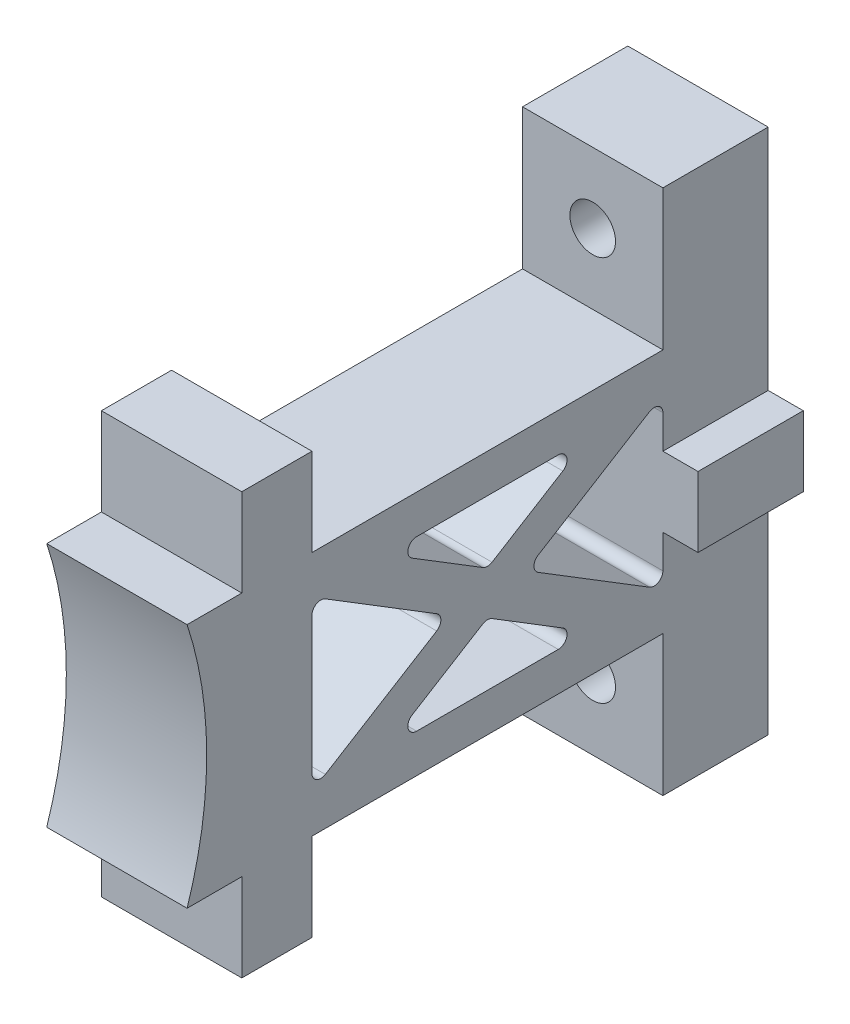
from build123d import *

# Parameters (mm, degrees)
BOSS_EXTRUDE1_DEPTH = 10.16
CUT_EXTRUDE1_DEPTH  = 21.32
SKETCH3_R           = 3.302
CUT_EXTRUDE2_DEPTH  = 16.24
SKETCH4_W           = 15.24
SKETCH4_H           = 10.16
BOSS_EXTRUDE2_DEPTH = 5.08


with BuildPart() as part:
    # Sketch1 → Boss-Extrude1 (new body, symmetric)
    with BuildSketch(Plane(origin=(0, 0, 0), x_dir=(0, 0, -1), z_dir=(1, 0, 0))):
        with BuildLine():
            Line((54.313848142, 17.78), (62.23, 17.78))
            Line((62.23, 17.78), (62.23, 30.48))
            Line((62.23, 30.48), (72.39, 30.48))
            Line((72.39, 30.48), (72.39, 17.78))
            Line((72.39, 17.78), (123.19, 17.78))
            Line((123.19, 17.78), (123.19, 38.1))
            Line((123.19, 38.1), (138.43, 38.1))
            Line((138.43, 38.1), (138.43, -38.1))
            Line((138.43, -38.1), (123.19, -38.1))
            Line((123.19, -38.1), (123.19, -17.78))
            Line((123.19, -17.78), (72.39, -17.78))
            Line((72.39, -17.78), (72.39, -30.48))
            Line((72.39, -30.48), (62.23, -30.48))
            Line((62.23, -30.48), (62.23, -17.78))
            Line((62.23, -17.78), (54.313848142, -17.78))
            ThreePointArc((54.313848142, -17.78), (57.15, 0), (54.313848142, 17.78))
        make_face()
    extrude(amount=BOSS_EXTRUDE1_DEPTH, both=True)

    # Sketch2 → Cut-Extrude1 (cut, through all)
    with BuildSketch(Plane(origin=(10.16, 0, 0), x_dir=(0, 0, -1), z_dir=(1, 0, 0))):
        with BuildLine():
            Line((72.39, 9.91925318), (72.39, -9.91925318))
            ThreePointArc((72.39, -9.91925318), (73.040490814, -11.02790478), (74.325603731, -11.000859243))
            Line((74.325603731, -11.000859243), (90.444390149, -1.081606062))
            ThreePointArc((90.444390149, -1.081606062), (91.048786418, 0), (90.444390149, 1.081606062))
            Line((90.444390149, 1.081606062), (74.325603731, 11.000859243))
            ThreePointArc((74.325603731, 11.000859243), (73.040490814, 11.02790478), (72.39, 9.91925318))
        make_face()
        with BuildLine():
            Line((123.19, 9.91925318), (123.19, -9.91925318))
            ThreePointArc((123.19, -9.91925318), (122.539509186, -11.02790478), (121.254396269, -11.000859243))
            Line((121.254396269, -11.000859243), (105.135609851, -1.081606062))
            ThreePointArc((105.135609851, -1.081606062), (104.531213582, 0), (105.135609851, 1.081606062))
            Line((105.135609851, 1.081606062), (121.254396269, 11.000859243))
            ThreePointArc((121.254396269, 11.000859243), (122.539509186, 11.02790478), (123.19, 9.91925318))
        make_face()
        with BuildLine():
            Line((86.873499611, 9.840393938), (97.124396269, 3.53214984))
            ThreePointArc((97.124396269, 3.53214984), (97.79, 3.343755902), (98.455603731, 3.53214984))
            Line((98.455603731, 3.53214984), (108.706500389, 9.840393938))
            ThreePointArc((108.706500389, 9.840393938), (109.262890869, 11.267875918), (108.040896659, 12.192))
            Line((108.040896659, 12.192), (87.539103341, 12.192))
            ThreePointArc((87.539103341, 12.192), (86.317109131, 11.267875918), (86.873499611, 9.840393938))
        make_face()
        with BuildLine():
            Line((87.539103341, -12.192), (108.040896659, -12.192))
            ThreePointArc((108.040896659, -12.192), (109.262890869, -11.267875918), (108.706500389, -9.840393938))
            Line((108.706500389, -9.840393938), (98.455603731, -3.53214984))
            ThreePointArc((98.455603731, -3.53214984), (97.79, -3.343755902), (97.124396269, -3.53214984))
            Line((97.124396269, -3.53214984), (86.873499611, -9.840393938))
            ThreePointArc((86.873499611, -9.840393938), (86.317109131, -11.267875918), (87.539103341, -12.192))
        make_face()
    extrude(amount=-CUT_EXTRUDE1_DEPTH, mode=Mode.SUBTRACT)

    # Sketch3 → Cut-Extrude2 (cut, through all)
    with BuildSketch(Plane.XY.offset(-123.19)):
        with Locations((0, 27.94)):
            Circle(SKETCH3_R)
        with Locations((0, -27.94)):
            Circle(SKETCH3_R)
    extrude(amount=-CUT_EXTRUDE2_DEPTH, mode=Mode.SUBTRACT)

    # Sketch4 → Boss-Extrude2 (add)
    with BuildSketch(Plane(origin=(10.16, 0, 0), x_dir=(0, 0, -1), z_dir=(1, 0, 0))):
        with Locations((130.81, 0)):
            Rectangle(SKETCH4_W, SKETCH4_H)
    extrude(amount=BOSS_EXTRUDE2_DEPTH)


solid = part.part
